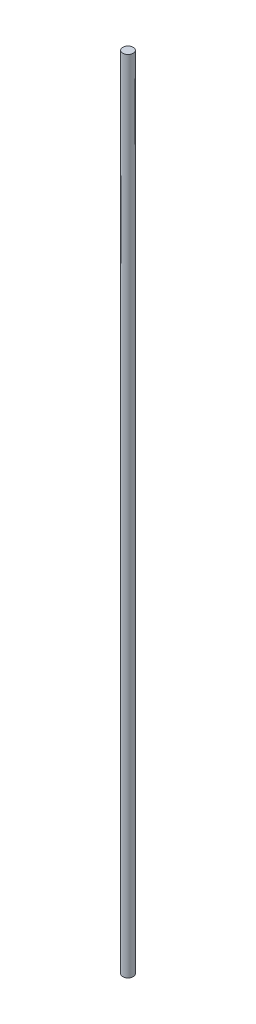
from build123d import *

# Parameters (mm, degrees)
CROQUIS1_R = 6.35


with BuildPart() as part:
    # Barrer1: sweep along a path in Croquis2
    with BuildLine(Plane.XY) as barrer1_path:
        Line((0, 0), (0, 980))
    # Croquis1 → Barrer1 (sweep)
    with BuildSketch(Plane(origin=(0, 0, 0), x_dir=(1, 0, 0), z_dir=(0, 1, 0))):
        Circle(CROQUIS1_R)
    sweep(path=barrer1_path.line)


solid = part.part
